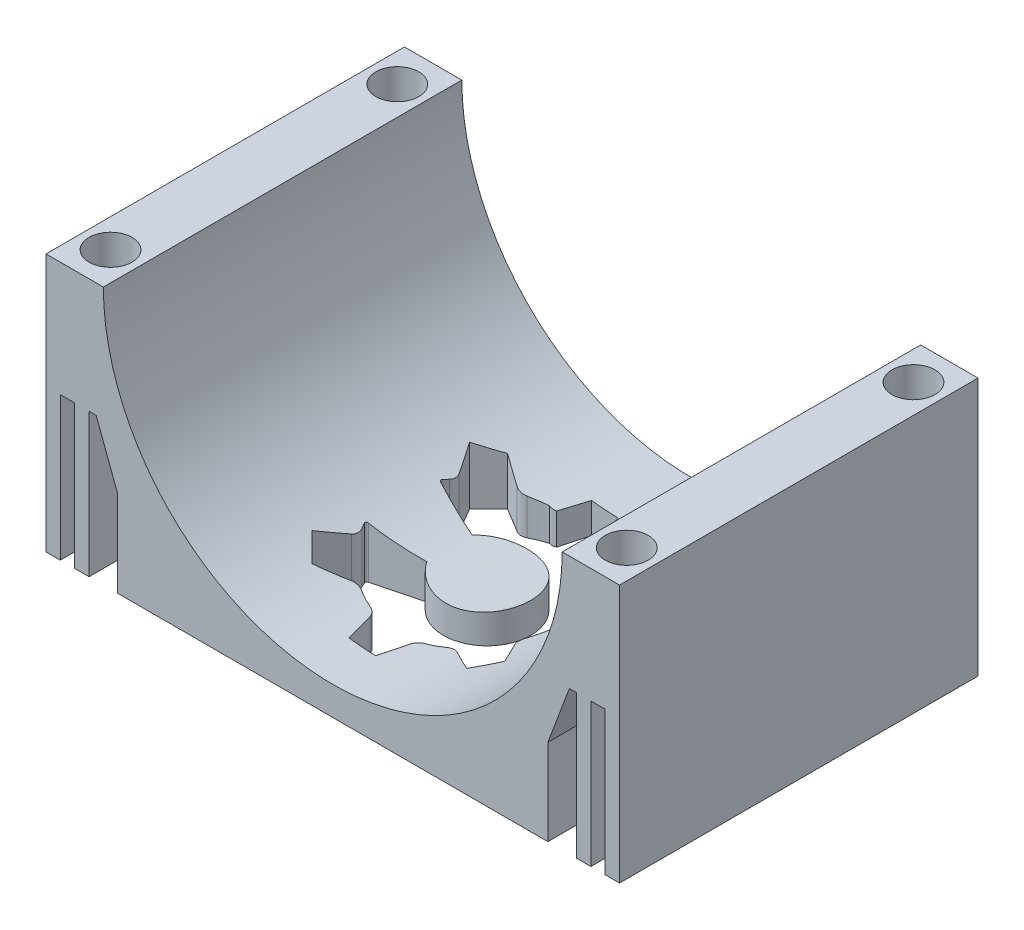
from build123d import *

# Parameters (mm, degrees)
CROQUIS1_W              = 40
CROQUIS1_H              = 25
SALIENTE_EXTRUIR1_DEPTH = 18
CROQUIS2_R              = 16
CORTAR_EXTRUIR1_DEPTH   = 26
CROQUIS3_R              = 1.5
CORTAR_EXTRUIR2_DEPTH   = 19
CORTAR_EXTRUIR3_DEPTH   = 10
SALIENTE_EXTRUIR2_DEPTH = 25
CROQUIS6_W              = 1
CROQUIS6_H              = 25
SALIENTE_EXTRUIR3_DEPTH = 10


with BuildPart() as part:
    # Croquis1 → Saliente-Extruir1 (new body)
    with BuildSketch(Plane(origin=(0, 0, 0), x_dir=(1, 0, 0), z_dir=(0, 1, 0))):
        with Locations((20, 12.5)):
            Rectangle(CROQUIS1_W, CROQUIS1_H)
    extrude(amount=SALIENTE_EXTRUIR1_DEPTH)

    # Croquis2 → Cortar-Extruir1 (cut, through all)
    with BuildSketch(Plane.XY):
        with Locations((20, 18)):
            Circle(CROQUIS2_R)
    extrude(amount=-CORTAR_EXTRUIR1_DEPTH, mode=Mode.SUBTRACT)

    # Croquis3 → Cortar-Extruir2 (cut, through all)
    with BuildSketch(Plane(origin=(0, 18, 0), x_dir=(1, 0, 0), z_dir=(0, 1, 0))):
        with Locations((2, 2.5)):
            Circle(CROQUIS3_R)
        with Locations((2, 22.5)):
            Circle(CROQUIS3_R)
        with Locations((38, 2.5)):
            Circle(CROQUIS3_R)
        with Locations((38, 22.5)):
            Circle(CROQUIS3_R)
    extrude(amount=-CORTAR_EXTRUIR2_DEPTH, mode=Mode.SUBTRACT)

    # Croquis4 → Cortar-Extruir3 (cut)
    with BuildSketch(Plane.XZ):
        with BuildLine():
            Line((12.088237667, -6.478545635), (13.401635398, -5.142871626))
            Line((13.401635398, -5.142871626), (15.124961017, -6.145817155))
            ThreePointArc((15.124961017, -6.145817155), (15.475165724, -6.243431571), (15.828418521, -6.157499195))
            ThreePointArc((15.828418521, -6.157499195), (16.370055517, -5.897538787), (16.933440791, -5.688859407))
            ThreePointArc((16.933440791, -5.688859407), (17.240768872, -5.494639527), (17.414026723, -5.175024714))
            Line((17.414026723, -5.175024714), (17.890921137, -3.238966182))
            Line((17.890921137, -3.238966182), (19.764097728, -3.223214474))
            Line((19.764097728, -3.223214474), (20.273483375, -5.15097929))
            ThreePointArc((20.273483375, -5.15097929), (20.452091683, -5.467635229), (20.762642496, -5.656659312))
            ThreePointArc((20.762642496, -5.656659312), (21.329457457, -5.855834737), (21.875389609, -6.10664968))
            ThreePointArc((21.875389609, -6.10664968), (22.230037574, -6.186629256), (22.578551176, -6.083139256))
            Line((22.578551176, -6.083139256), (24.284766568, -5.051354413))
            Line((24.284766568, -5.051354413), (25.620440577, -6.364752144))
            Line((25.620440577, -6.364752144), (24.617495048, -8.088077763))
            ThreePointArc((24.617495048, -8.088077763), (24.519880632, -8.43828247), (24.605813007, -8.791535267))
            ThreePointArc((24.605813007, -8.791535267), (24.865773416, -9.333172263), (25.074452795, -9.896557537))
            ThreePointArc((25.074452795, -9.896557537), (25.268672676, -10.203885618), (25.588287488, -10.377143469))
            Line((25.588287488, -10.377143469), (27.524346021, -10.854037883))
            Line((27.524346021, -10.854037883), (27.540097728, -12.727214474))
            Line((27.540097728, -12.727214474), (25.612332912, -13.236600121))
            ThreePointArc((25.612332912, -13.236600121), (25.295676973, -13.415208429), (25.106652891, -13.725759242))
            ThreePointArc((25.106652891, -13.725759242), (24.907477465, -14.292574203), (24.656662522, -14.838506355))
            ThreePointArc((24.656662522, -14.838506355), (24.576682946, -15.19315432), (24.680172947, -15.541667922))
            Line((24.680172947, -15.541667922), (25.711957789, -17.247883314))
            Line((25.711957789, -17.247883314), (24.398560059, -18.583557323))
            Line((24.398560059, -18.583557323), (22.67523444, -17.580611794))
            ThreePointArc((22.67523444, -17.580611794), (22.325029732, -17.482997378), (21.971776936, -17.568929753))
            ThreePointArc((21.971776936, -17.568929753), (21.430139939, -17.828890162), (20.866754665, -18.037569541))
            ThreePointArc((20.866754665, -18.037569541), (20.6241928, -18.009408471), (20.386168733, -18.063941468))
            Line((20.386168733, -18.063941468), (19.909274319, -20))
            Line((19.909274319, -20), (18.036097728, -20.015751708))
            Line((18.036097728, -20.015751708), (17.526712081, -18.087986892))
            ThreePointArc((17.526712081, -18.087986892), (17.283728175, -18.036032676), (17.03755296, -18.069769637))
            ThreePointArc((17.03755296, -18.069769637), (16.470737999, -17.870594211), (15.924805848, -17.619779268))
            ThreePointArc((15.924805848, -17.619779268), (15.570157883, -17.539799692), (15.22164428, -17.643289693))
            Line((15.22164428, -17.643289693), (13.515428889, -18.675074535))
            Line((13.515428889, -18.675074535), (12.17975488, -17.361676805))
            Line((12.17975488, -17.361676805), (13.182700409, -15.638351186))
            ThreePointArc((13.182700409, -15.638351186), (13.280314825, -15.288146478), (13.194382449, -14.934893682))
            ThreePointArc((13.194382449, -14.934893682), (13.1083452, -14.769415199), (13.027105933, -14.601529171))
            ThreePointArc((13.027105933, -14.601529171), (13.02605148, -14.489666601), (13.109673231, -14.415358127))
            Line((13.109673231, -14.415358127), (16.284140051, -13.434659859))
            ThreePointArc((16.284140051, -13.434659859), (21.951688309, -11.884896122), (16.306733365, -10.25475669))
            Line((16.306733365, -10.25475669), (13.070699975, -9.410888594))
            ThreePointArc((13.070699975, -9.410888594), (12.983034926, -9.338706443), (12.981392618, -9.2251603))
            ThreePointArc((12.981392618, -9.2251603), (13.060028024, -9.055370844), (13.143532934, -8.887922594))
            ThreePointArc((13.143532934, -8.887922594), (13.22351251, -8.533274629), (13.12002251, -8.184761026))
            Line((13.12002251, -8.184761026), (12.088237667, -6.478545635))
        make_face()
        Polygon((5, -20), (5, -25), (0, -25), (0, -20), (0, -5), (0, 0), (5, 0), (5, -5), align=None)
        Polygon((35, 0), (35, -5), (35, -20), (35, -25), (40, -25), (40, -20), (40, -5), (40, 0), align=None)
    extrude(amount=-CORTAR_EXTRUIR3_DEPTH, mode=Mode.SUBTRACT)

    # Croquis5 → Saliente-Extruir2 (add)
    with BuildSketch(Plane(origin=(0, 0, -25), x_dir=(-1, 0, 0), z_dir=(0, 0, -1))):
        Polygon((-5, 10), (-5, 6), (-3.5, 10), align=None)
        Polygon((-35, 10), (-35, 6), (-36.5, 10), align=None)
    extrude(amount=-SALIENTE_EXTRUIR2_DEPTH)

    # Croquis6 → Saliente-Extruir3 (add)
    with BuildSketch(Plane.XZ.offset(-10)):
        with Locations((0.5, -12.5)):
            Rectangle(CROQUIS6_W, CROQUIS6_H)
        with Locations((39.5, -12.5)):
            Rectangle(CROQUIS6_W, CROQUIS6_H)
        with Locations((2.5, -12.5)):
            Rectangle(CROQUIS6_W, CROQUIS6_H)
        with Locations((37.5, -12.5)):
            Rectangle(CROQUIS6_W, CROQUIS6_H)
    extrude(amount=SALIENTE_EXTRUIR3_DEPTH)


solid = part.part
